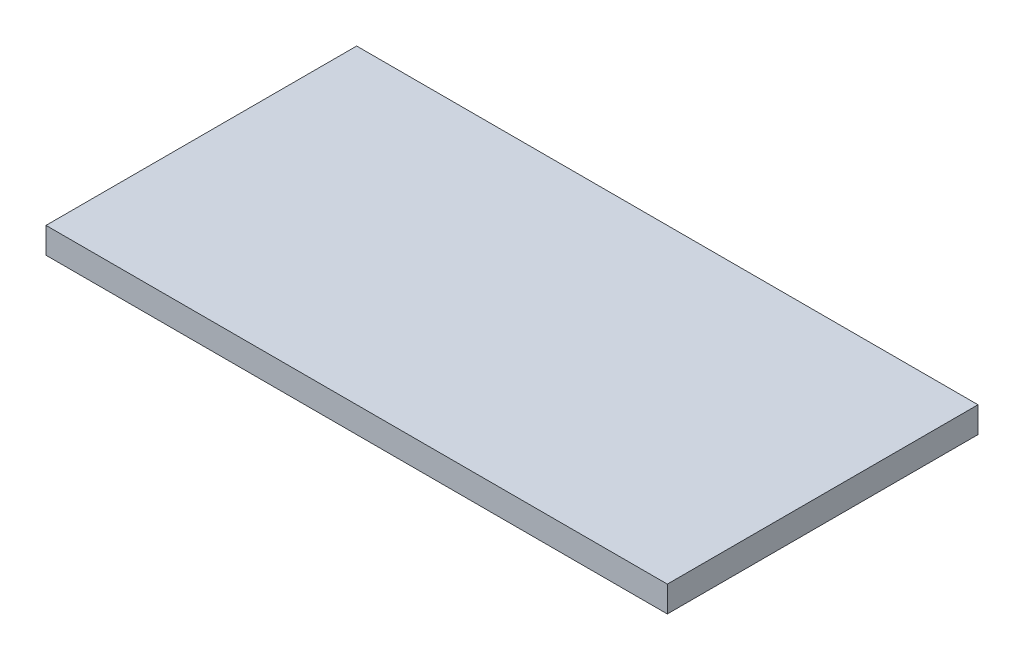
from build123d import *

# Parameters (mm, degrees)
SKETCH_1_W      = 1200
SKETCH_1_H      = 600
EXTRUDE_1_DEPTH = 50


with BuildPart() as part:
    # Эскиз1 → Бобышка-Вытянуть1 (new body)
    with BuildSketch(Plane(origin=(0, 0, 0), x_dir=(1, 0, 0), z_dir=(0, 1, 0))):
        with Locations((600, 300)):
            Rectangle(SKETCH_1_W, SKETCH_1_H)
    extrude(amount=EXTRUDE_1_DEPTH)


solid = part.part
